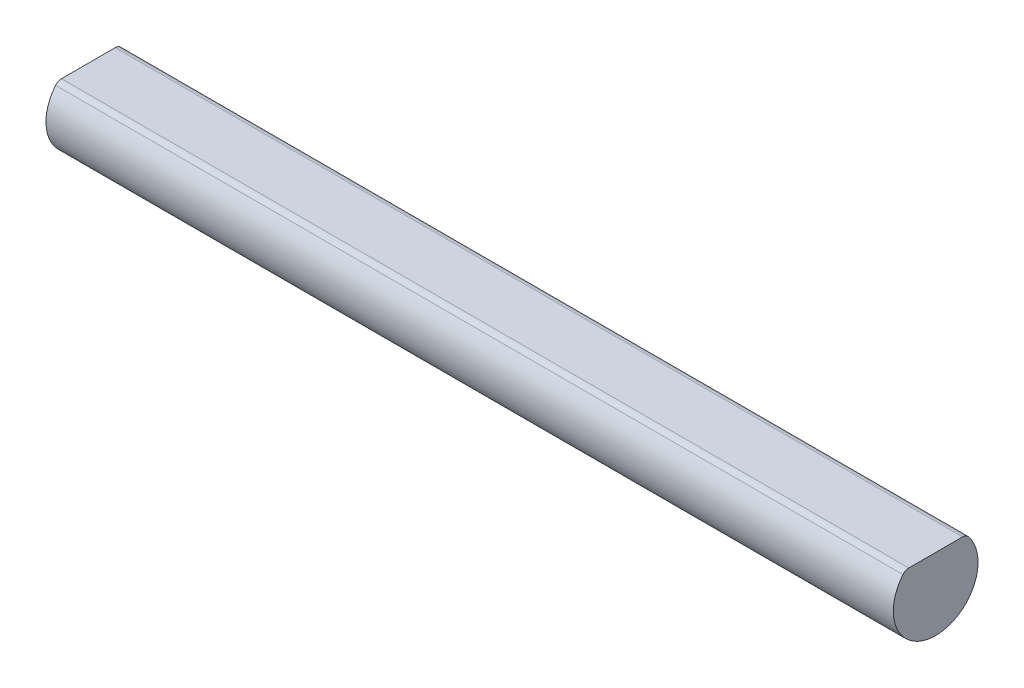
from build123d import *

# Parameters (mm, degrees)
SKETCH1_R           = 5
BOSS_EXTRUDE1_DEPTH = 100
SKETCH2_W           = 5.740134486
SKETCH2_H           = 2.400249814
SKETCH2_W_2         = 4.427188802
CUT_EXTRUDE1_DEPTH  = 101
FILLET1_R           = 0.9


with BuildPart() as part:
    # Sketch1 → Boss-Extrude1 (new body)
    with BuildSketch(Plane(origin=(0, 0, 0), x_dir=(0, 0, -1), z_dir=(1, 0, 0))):
        Circle(SKETCH1_R)
    extrude(amount=BOSS_EXTRUDE1_DEPTH)

    # Sketch2 → Cut-Extrude1 (cut, through all)
    with BuildSketch(Plane(origin=(100, 0, 0), x_dir=(0, 0, -1), z_dir=(1, 0, 0))):
        with Locations((-2.870067243, 4.700124907)):
            Rectangle(SKETCH2_W, SKETCH2_H)
        with Locations((2.213594401, 4.700124907)):
            Rectangle(SKETCH2_W_2, SKETCH2_H)
    extrude(amount=-CUT_EXTRUDE1_DEPTH, mode=Mode.SUBTRACT)

    # Fillet1
    fillet1_edges = [part.edges().sort_by_distance(p)[0] for p in [
        (50, 3.5, -3.570714214),
        (50, 3.5, 3.570714214),
    ]]
    fillet(fillet1_edges, radius=FILLET1_R)


solid = part.part
